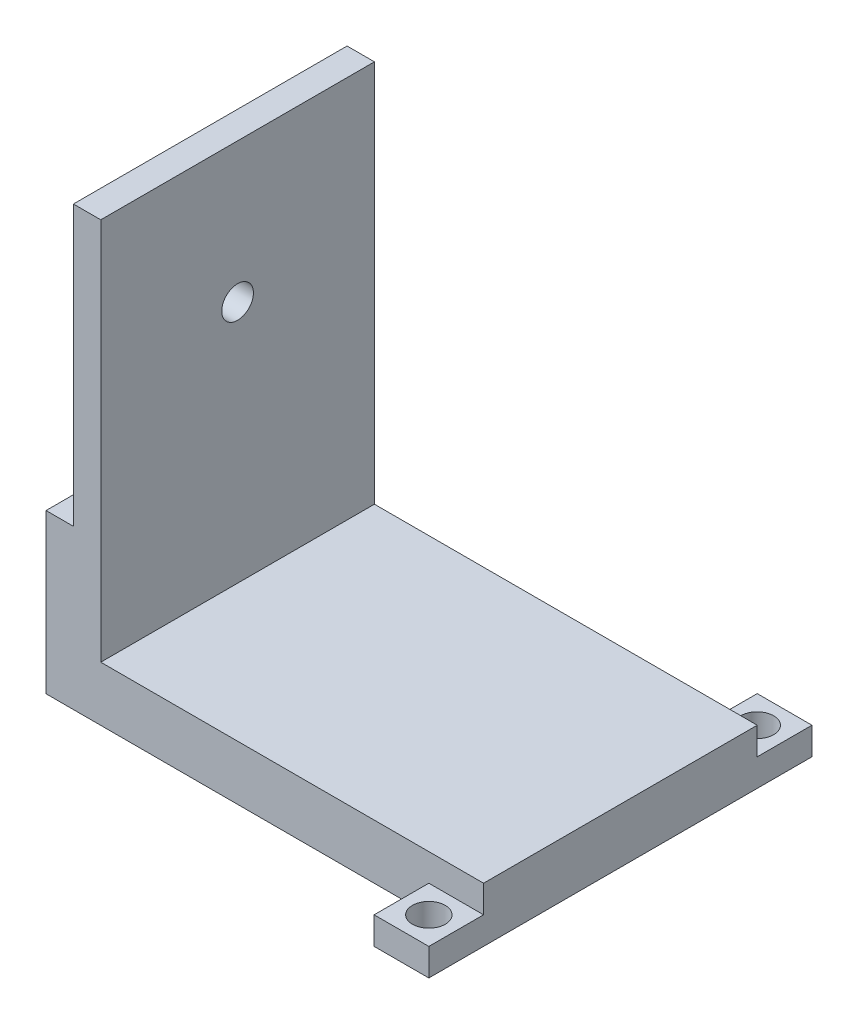
from build123d import *

# Parameters (mm, degrees)
SKETCH1_W           = 79939.164357761
SKETCH1_H           = 50000
BOSS_EXTRUDE2_DEPTH = 10000
SKETCH5_W           = 9997.561237483
SKETCH5_H           = 10000
BOSS_EXTRUDE3_DEPTH = 10000
SKETCH6_W           = 9997.561237483
SKETCH6_H           = 10000
CUT_EXTRUDE1_DEPTH  = 5000
SKETCH9_W           = 10000
SKETCH9_H           = 10000
BOSS_EXTRUDE5_DEPTH = 10000
SKETCH11_W          = 10000
SKETCH11_H          = 10000
CUT_EXTRUDE3_DEPTH  = 5000
SKETCH13_R          = 3000
CUT_EXTRUDE5_DEPTH  = 5000
SKETCH14_R          = 3000
CUT_EXTRUDE6_DEPTH  = 5000
SKETCH15_W          = 10000
SKETCH15_H          = 50000
BOSS_EXTRUDE6_DEPTH = 70000
SKETCH16_W          = 50000
SKETCH16_H          = 51000
CUT_EXTRUDE7_DEPTH  = 5000
SKETCH17_R          = 2894.024625878
CUT_EXTRUDE8_DEPTH  = 5000


with BuildPart() as part:
    # Sketch1 → Boss-Extrude2 (new body)
    with BuildSketch(Plane(origin=(0, 0, 0), x_dir=(1, 0, 0), z_dir=(0, 1, 0))):
        with Locations((37675.205465908, 769.824887906)):
            Rectangle(SKETCH1_W, SKETCH1_H)
    extrude(amount=BOSS_EXTRUDE2_DEPTH)

    # Sketch5 → Boss-Extrude3 (add)
    with BuildSketch(Plane.XY.offset(24230.175112094)):
        with Locations((72646.007026047, 5000)):
            Rectangle(SKETCH5_W, SKETCH5_H)
    extrude(amount=BOSS_EXTRUDE3_DEPTH)

    # Sketch6 → Cut-Extrude1 (cut)
    with BuildSketch(Plane(origin=(0, 10000, 0), x_dir=(1, 0, 0), z_dir=(0, 1, 0))):
        with Locations((72646.007026047, -29230.175112094)):
            Rectangle(SKETCH6_W, SKETCH6_H)
    extrude(amount=-CUT_EXTRUDE1_DEPTH, mode=Mode.SUBTRACT)

    # Sketch9 → Boss-Extrude5 (add)
    with BuildSketch(Plane(origin=(0, 0, -25769.824887906), x_dir=(-1, 0, 0), z_dir=(0, 0, -1))):
        with Locations((-72644.787644788, 5000)):
            Rectangle(SKETCH9_W, SKETCH9_H)
    extrude(amount=BOSS_EXTRUDE5_DEPTH)

    # Sketch11 → Cut-Extrude3 (cut)
    with BuildSketch(Plane(origin=(0, 10000, 0), x_dir=(1, 0, 0), z_dir=(0, 1, 0))):
        with Locations((72644.787644788, 30769.824887906)):
            Rectangle(SKETCH11_W, SKETCH11_H)
    extrude(amount=-CUT_EXTRUDE3_DEPTH, mode=Mode.SUBTRACT)

    # Sketch13 → Cut-Extrude5 (cut)
    with BuildSketch(Plane(origin=(0, 5000, 0), x_dir=(1, 0, 0), z_dir=(0, 1, 0))):
        with Locations((72646.007026046, -29230.175112094)):
            Circle(SKETCH13_R)
    extrude(amount=-CUT_EXTRUDE5_DEPTH, mode=Mode.SUBTRACT)

    # Sketch14 → Cut-Extrude6 (cut)
    with BuildSketch(Plane(origin=(0, 5000, 0), x_dir=(1, 0, 0), z_dir=(0, 1, 0))):
        with Locations((72644.787644788, 30769.824887906)):
            Circle(SKETCH14_R)
    extrude(amount=-CUT_EXTRUDE6_DEPTH, mode=Mode.SUBTRACT)

    # Sketch15 → Boss-Extrude6 (add)
    with BuildSketch(Plane(origin=(0, 10000, 0), x_dir=(1, 0, 0), z_dir=(0, 1, 0))):
        with Locations((2705.623287027, 769.824887906)):
            Rectangle(SKETCH15_W, SKETCH15_H)
    extrude(amount=BOSS_EXTRUDE6_DEPTH)

    # Sketch16 → Cut-Extrude7 (cut)
    with BuildSketch(Plane.ZY.offset(2294.376712973)):
        with Locations((-769.824887906, 54500)):
            Rectangle(SKETCH16_W, SKETCH16_H)
    extrude(amount=-CUT_EXTRUDE7_DEPTH, mode=Mode.SUBTRACT)

    # Sketch17 → Cut-Extrude8 (cut)
    with BuildSketch(Plane.ZY.offset(-2705.623287027)):
        with Locations((-769.824887906, 54500)):
            Circle(SKETCH17_R)
    extrude(amount=-CUT_EXTRUDE8_DEPTH, mode=Mode.SUBTRACT)


solid = part.part
